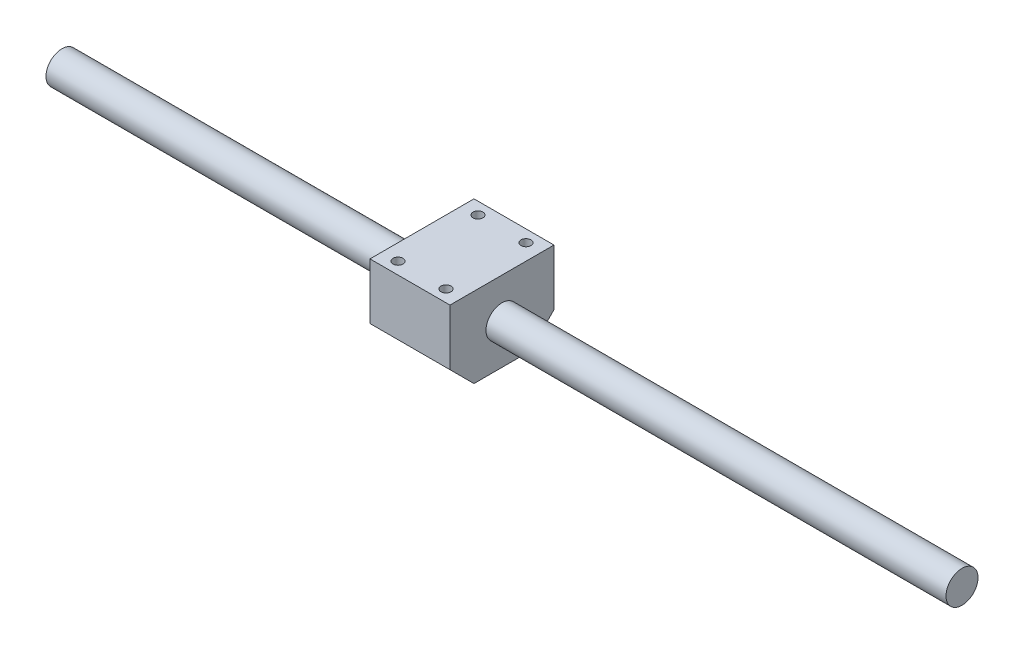
from build123d import *

# Parameters (mm, degrees)
SKETCH1_R           = 8
BOSS_EXTRUDE1_DEPTH = 450
SKETCH2_W           = 40
SKETCH2_H           = 52
BOSS_EXTRUDE2_DEPTH = 20
CHAMFER1_SIZE       = 12
SKETCH3_R           = 2.5
CUT_EXTRUDE1_DEPTH  = 10


with BuildPart() as part:
    # Sketch1 → Boss-Extrude1 (new body)
    with BuildSketch(Plane(origin=(0, 0, 0), x_dir=(0, 0, -1), z_dir=(1, 0, 0))):
        Circle(SKETCH1_R)
    extrude(amount=BOSS_EXTRUDE1_DEPTH)

    # Sketch2 → Boss-Extrude2 (add, symmetric)
    with BuildSketch(Plane(origin=(0, 0, 0), x_dir=(1, 0, 0), z_dir=(0, 1, 0))):
        with Locations((200, 0)):
            Rectangle(SKETCH2_W, SKETCH2_H)
    extrude(amount=BOSS_EXTRUDE2_DEPTH, both=True)

    # Chamfer1
    chamfer1_edges = [part.edges().sort_by_distance(p)[0] for p in [
        (200, -20, 26),
        (200, -20, -26),
    ]]
    chamfer(chamfer1_edges, length=CHAMFER1_SIZE)

    # Sketch3 → Cut-Extrude1 (cut)
    with BuildSketch(Plane(origin=(0, 20, 0), x_dir=(1, 0, 0), z_dir=(0, 1, 0))):
        with Locations((188, 20)):
            Circle(SKETCH3_R)
        with Locations((212, 20)):
            Circle(SKETCH3_R)
        with Locations((188, -20)):
            Circle(SKETCH3_R)
        with Locations((212, -20)):
            Circle(SKETCH3_R)
    extrude(amount=-CUT_EXTRUDE1_DEPTH, mode=Mode.SUBTRACT)


solid = part.part
